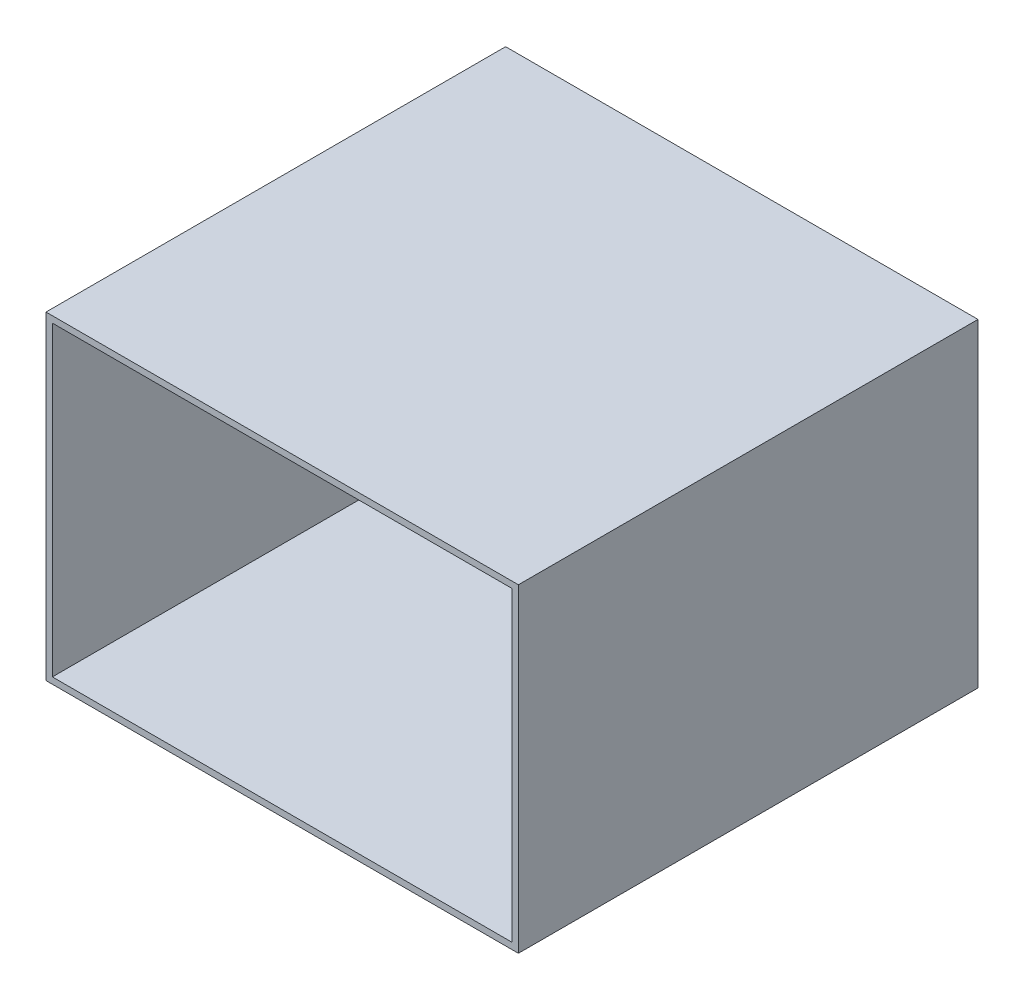
from build123d import *

# Parameters (mm, degrees)
SKETCH1_W           = 457.2
SKETCH1_H           = 304.8
SKETCH1_R           = 25.4
CHAMBER_BASE_DEPTH  = 6.35
SKETCH2_W           = 457.2
SKETCH2_H           = 304.8
BACK_WALL_DEPTH     = 6.35
SKETCH3_W           = 463.55
SKETCH3_H           = 457.2
SIDE_WALL_2_DEPTH   = 6.35
SKETCH5_W           = 463.55
SKETCH5_H           = 457.2
SIDE_WALL_3_DEPTH   = 6.35
SKETCH6_W           = 457.2
SKETCH6_H           = 317.5
BOSS_EXTRUDE1_DEPTH = 6.35
CUT_EXTRUDE1_DEPTH  = 6.35


with BuildPart() as part:
    # Sketch1 → Chamber Base (new body)
    with BuildSketch(Plane.XY):
        with Locations((228.6, 152.4)):
            Rectangle(SKETCH1_W, SKETCH1_H)
        with Locations((228.6, 152.4)):
            Circle(SKETCH1_R, mode=Mode.SUBTRACT)
    extrude(amount=CHAMBER_BASE_DEPTH)

    # Sketch2 → Back wall (add)
    with BuildSketch(Plane(origin=(457.2, 0, 0), x_dir=(0, 0, -1), z_dir=(1, 0, 0))):
        with Locations((-228.6, 152.4)):
            Rectangle(SKETCH2_W, SKETCH2_H)
    extrude(amount=BACK_WALL_DEPTH)

    # Sketch3 → Side wall 2 (add)
    with BuildSketch(Plane(origin=(0, 304.8, 0), x_dir=(1, 0, 0), z_dir=(0, 1, 0))):
        with Locations((231.775, -228.6)):
            Rectangle(SKETCH3_W, SKETCH3_H)
    extrude(amount=SIDE_WALL_2_DEPTH)

    # Sketch5 → Side wall 3 (add)
    with BuildSketch(Plane.XZ):
        with Locations((231.775, 228.6)):
            Rectangle(SKETCH5_W, SKETCH5_H)
    extrude(amount=SIDE_WALL_3_DEPTH)

    # Sketch6 → Boss-Extrude1 (add)
    with BuildSketch(Plane.ZY):
        with Locations((228.6, 152.4)):
            Rectangle(SKETCH6_W, SKETCH6_H)
    extrude(amount=BOSS_EXTRUDE1_DEPTH)

    # Sketch7 → Cut-Extrude1 (cut)
    with BuildSketch(Plane(origin=(0, 0, 0), x_dir=(-1, 0, 0), z_dir=(0, 0, -1))):
        with BuildLine():
            Line((-429.73498, 279.4), (-421.16502, 279.4))
            ThreePointArc((-421.16502, 279.4), (-419.704830355, 278.795169645), (-419.1, 277.33498))
            Line((-419.1, 277.33498), (-419.1, 268.76502))
            ThreePointArc((-419.1, 268.76502), (-419.704830355, 267.304830355), (-421.16502, 266.7))
            Line((-421.16502, 266.7), (-429.73498, 266.7))
            ThreePointArc((-429.73498, 266.7), (-431.195169645, 267.304830355), (-431.8, 268.76502))
            Line((-431.8, 268.76502), (-431.8, 277.33498))
            ThreePointArc((-431.8, 277.33498), (-431.195169645, 278.795169645), (-429.73498, 279.4))
        make_face()
        with BuildLine():
            Line((-38.1, 277.33498), (-38.1, 268.76502))
            ThreePointArc((-38.1, 268.76502), (-37.495169645, 267.304830355), (-36.03498, 266.7))
            Line((-36.03498, 266.7), (-27.46502, 266.7))
            ThreePointArc((-27.46502, 266.7), (-26.004830355, 267.304830355), (-25.4, 268.76502))
            Line((-25.4, 268.76502), (-25.4, 277.33498))
            ThreePointArc((-25.4, 277.33498), (-26.004830355, 278.795169645), (-27.46502, 279.4))
            Line((-27.46502, 279.4), (-36.03498, 279.4))
            ThreePointArc((-36.03498, 279.4), (-37.495169645, 278.795169645), (-38.1, 277.33498))
        make_face()
        with BuildLine():
            Line((-27.46502, 25.4), (-36.03498, 25.4))
            ThreePointArc((-36.03498, 25.4), (-37.495169645, 26.004830355), (-38.1, 27.46502))
            Line((-38.1, 27.46502), (-38.1, 36.03498))
            ThreePointArc((-38.1, 36.03498), (-37.495169645, 37.495169645), (-36.03498, 38.1))
            Line((-36.03498, 38.1), (-27.46502, 38.1))
            ThreePointArc((-27.46502, 38.1), (-26.004830355, 37.495169645), (-25.4, 36.03498))
            Line((-25.4, 36.03498), (-25.4, 27.46502))
            ThreePointArc((-25.4, 27.46502), (-26.004830355, 26.004830355), (-27.46502, 25.4))
        make_face()
        with BuildLine():
            Line((-419.1, 27.46502), (-419.1, 36.03498))
            ThreePointArc((-419.1, 36.03498), (-419.704830355, 37.495169645), (-421.16502, 38.1))
            Line((-421.16502, 38.1), (-429.73498, 38.1))
            ThreePointArc((-429.73498, 38.1), (-431.195169645, 37.495169645), (-431.8, 36.03498))
            Line((-431.8, 36.03498), (-431.8, 27.46502))
            ThreePointArc((-431.8, 27.46502), (-431.195169645, 26.004830355), (-429.73498, 25.4))
            Line((-429.73498, 25.4), (-421.16502, 25.4))
            ThreePointArc((-421.16502, 25.4), (-419.704830355, 26.004830355), (-419.1, 27.46502))
        make_face()
    extrude(amount=-CUT_EXTRUDE1_DEPTH, mode=Mode.SUBTRACT)


solid = part.part
